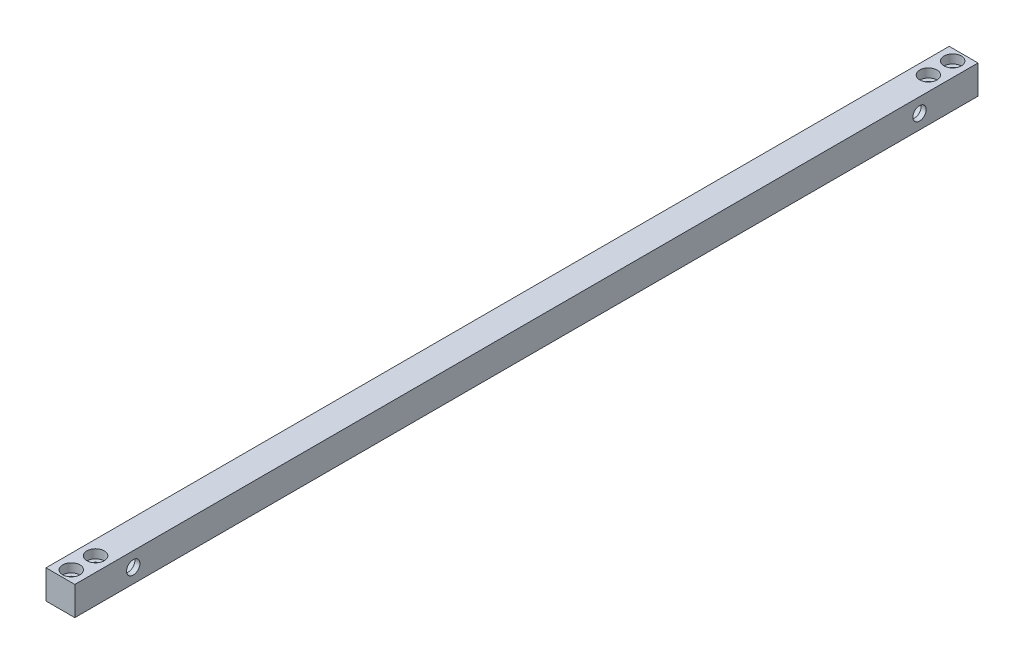
from build123d import *

# Parameters (mm, degrees)
SKETCH1_W                                       = 15.875
SKETCH1_H                                       = 15.875
BOSS_EXTRUDE1_DEPTH                             = 497.84
SKETCH8_R                                       = 6.8199
CUT_EXTRUDE1_DEPTH                              = 13.08608
L_0_29_DIAMETER_HOLE1_D                         = 7.366
L_0_29_DIAMETER_HOLE1_DEPTH                     = 50.8
L_0_29_DIAMETER_HOLE1_TIP                       = 2.21296966
CBORE_FOR_10_SOCKET_HEAD_CAP_SCREW1_D           = 4.9784
CBORE_FOR_10_SOCKET_HEAD_CAP_SCREW1_DEPTH       = 25.4
CBORE_FOR_10_SOCKET_HEAD_CAP_SCREW1_CBORE_D     = 9.525
CBORE_FOR_10_SOCKET_HEAD_CAP_SCREW1_CBORE_DEPTH = 4.826
CBORE_FOR_10_SOCKET_HEAD_CAP_SCREW1_TIP         = 1.495662253
CBORE_FOR_10_SOCKET_HEAD_CAP_SCREW2_D           = 4.9784
CBORE_FOR_10_SOCKET_HEAD_CAP_SCREW2_DEPTH       = 25.4
CBORE_FOR_10_SOCKET_HEAD_CAP_SCREW2_CBORE_D     = 9.525
CBORE_FOR_10_SOCKET_HEAD_CAP_SCREW2_CBORE_DEPTH = 4.826
CBORE_FOR_10_SOCKET_HEAD_CAP_SCREW2_TIP         = 1.495662253


with BuildPart() as part:
    # Sketch1 → Boss-Extrude1 (new body)
    with BuildSketch(Plane.XY):
        with Locations((7.9375, 7.9375)):
            Rectangle(SKETCH1_W, SKETCH1_H)
    extrude(amount=BOSS_EXTRUDE1_DEPTH)

    # Sketch8 → Cut-Extrude1 (cut)
    with BuildSketch(Plane.ZY):
        with Locations((465.6201, 7.9375)):
            Circle(SKETCH8_R)
        with Locations((32.2199, 7.9375)):
            Circle(SKETCH8_R)
    extrude(amount=-CUT_EXTRUDE1_DEPTH, mode=Mode.SUBTRACT)

    # L (0.29) Diameter Hole1
    with Locations(Plane.ZY.offset(-13.08608)):
        with Locations((32.2199, 7.9375), (465.6201, 7.9375)):
            Hole(L_0_29_DIAMETER_HOLE1_D / 2, depth=L_0_29_DIAMETER_HOLE1_DEPTH)
            with Locations((0, 0, -(L_0_29_DIAMETER_HOLE1_DEPTH + L_0_29_DIAMETER_HOLE1_TIP / 2))):  # 118° drill point
                Cone(0, L_0_29_DIAMETER_HOLE1_D / 2, L_0_29_DIAMETER_HOLE1_TIP, mode=Mode.SUBTRACT)

    # CBORE for #10 Socket Head Cap Screw1
    with Locations(Plane(origin=(412.874136144, 15.875, -1707.973131805), x_dir=(1, 0, 0), z_dir=(0, 1, 0))):
        with Locations((-404.936636144, -2199.813131805), (-404.936636144, -2186.413131805), (-871.661636144, -2186.413131805), (-871.661636144, -2199.813131805)):
            CounterBoreHole(CBORE_FOR_10_SOCKET_HEAD_CAP_SCREW1_D / 2, CBORE_FOR_10_SOCKET_HEAD_CAP_SCREW1_CBORE_D / 2, CBORE_FOR_10_SOCKET_HEAD_CAP_SCREW1_CBORE_DEPTH, depth=CBORE_FOR_10_SOCKET_HEAD_CAP_SCREW1_DEPTH)
            with Locations((0, 0, -(CBORE_FOR_10_SOCKET_HEAD_CAP_SCREW1_DEPTH + CBORE_FOR_10_SOCKET_HEAD_CAP_SCREW1_TIP / 2))):  # 118° drill point
                Cone(0, CBORE_FOR_10_SOCKET_HEAD_CAP_SCREW1_D / 2, CBORE_FOR_10_SOCKET_HEAD_CAP_SCREW1_TIP, mode=Mode.SUBTRACT)

    # CBORE for #10 Socket Head Cap Screw2
    with Locations(Plane(origin=(412.874136144, 15.875, -1707.973131805), x_dir=(1, 0, 0), z_dir=(0, 1, 0))):
        with Locations((-404.936636144, -1713.973131805), (-404.936636144, -1727.373131805), (-871.661636144, -1713.973131805), (-871.661636144, -1727.373131805)):
            CounterBoreHole(CBORE_FOR_10_SOCKET_HEAD_CAP_SCREW2_D / 2, CBORE_FOR_10_SOCKET_HEAD_CAP_SCREW2_CBORE_D / 2, CBORE_FOR_10_SOCKET_HEAD_CAP_SCREW2_CBORE_DEPTH, depth=CBORE_FOR_10_SOCKET_HEAD_CAP_SCREW2_DEPTH)
            with Locations((0, 0, -(CBORE_FOR_10_SOCKET_HEAD_CAP_SCREW2_DEPTH + CBORE_FOR_10_SOCKET_HEAD_CAP_SCREW2_TIP / 2))):  # 118° drill point
                Cone(0, CBORE_FOR_10_SOCKET_HEAD_CAP_SCREW2_D / 2, CBORE_FOR_10_SOCKET_HEAD_CAP_SCREW2_TIP, mode=Mode.SUBTRACT)


solid = part.part
